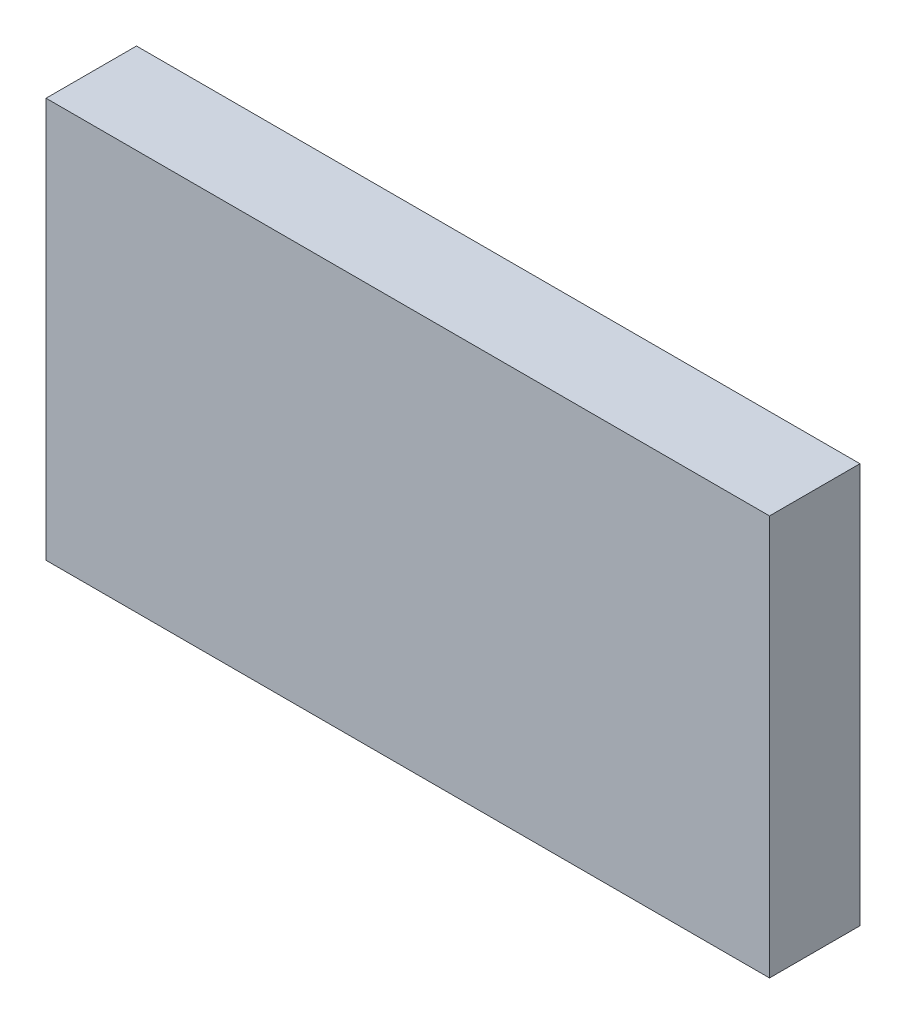
from build123d import *

# Parameters (mm, degrees)
SKETCH1_W           = 101.6
SKETCH1_H           = 12.7
BOSS_EXTRUDE1_DEPTH = 56.2


with BuildPart() as part:
    # Sketch1 → Boss-Extrude1 (new body)
    with BuildSketch(Plane(origin=(0, 0, 0), x_dir=(1, 0, 0), z_dir=(0, 1, 0))):
        with Locations((-50.8, 5.047435897)):
            Rectangle(SKETCH1_W, SKETCH1_H)
    extrude(amount=BOSS_EXTRUDE1_DEPTH)


solid = part.part
